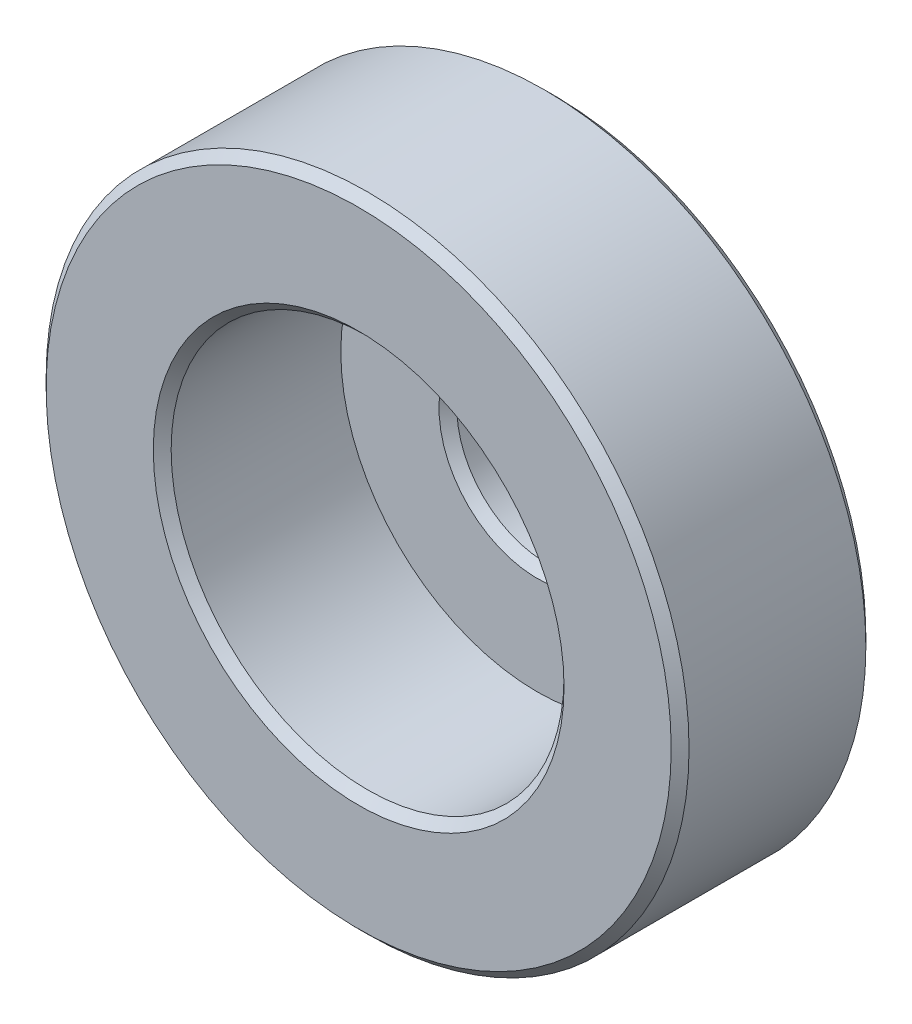
from build123d import *

# Parameters (mm, degrees)
CUT_EXTRUDE1_DEPTH = 1.5
CHAMFER1_SIZE      = 0.5


with BuildPart() as part:
    # Sketch2 → Revolve1 (revolve)
    with BuildSketch(Plane(origin=(0, 0, 0), x_dir=(1, 0, 0), z_dir=(0, 1, 0))):
        Polygon((-18, -4.5), (-11, -4.5), (-11, 0), (-5, 0), (-5, -5.4), (-11, -5.4), (-11, -15.4), (-18, -15.4), align=None)
    revolve(axis=Axis((0, 0, 0), (0, 0, 1)))

    # Sketch3 → Cut-Extrude1 (cut)
    with BuildSketch(Plane(origin=(0, 0, 0), x_dir=(-1, 0, 0), z_dir=(0, 0, -1))):
        with BuildLine():
            Line((1.25, 10.940968966), (1.25, 4.841229183))
            ThreePointArc((1.25, 4.841229183), (0, 5), (-1.25, 4.841229183))
            Line((-1.25, 4.841229183), (-1.25, 10.940968966))
            ThreePointArc((-1.25, 10.940968966), (0, 11.012143385), (1.25, 10.940968966))
        make_face()
        with BuildLine():
            Line((1.25, -4.841229183), (1.25, -10.940968966))
            ThreePointArc((1.25, -10.940968966), (0, -11.012143385), (-1.25, -10.940968966))
            Line((-1.25, -10.940968966), (-1.25, -4.841229183))
            ThreePointArc((-1.25, -4.841229183), (0, -5), (1.25, -4.841229183))
        make_face()
    extrude(amount=-CUT_EXTRUDE1_DEPTH, mode=Mode.SUBTRACT)

    # Chamfer1
    chamfer1_edges = [part.edges().sort_by_distance(p)[0] for p in [
        (11, 0, 0),
        (-8.20822758, -7.322909258, 0),
        (18, 0, 15.4),
        (18, 0, 4.5),
        (5, 0, 5.4),
        (11, 0, 15.4),
    ]]
    chamfer(chamfer1_edges, length=CHAMFER1_SIZE)


solid = part.part
